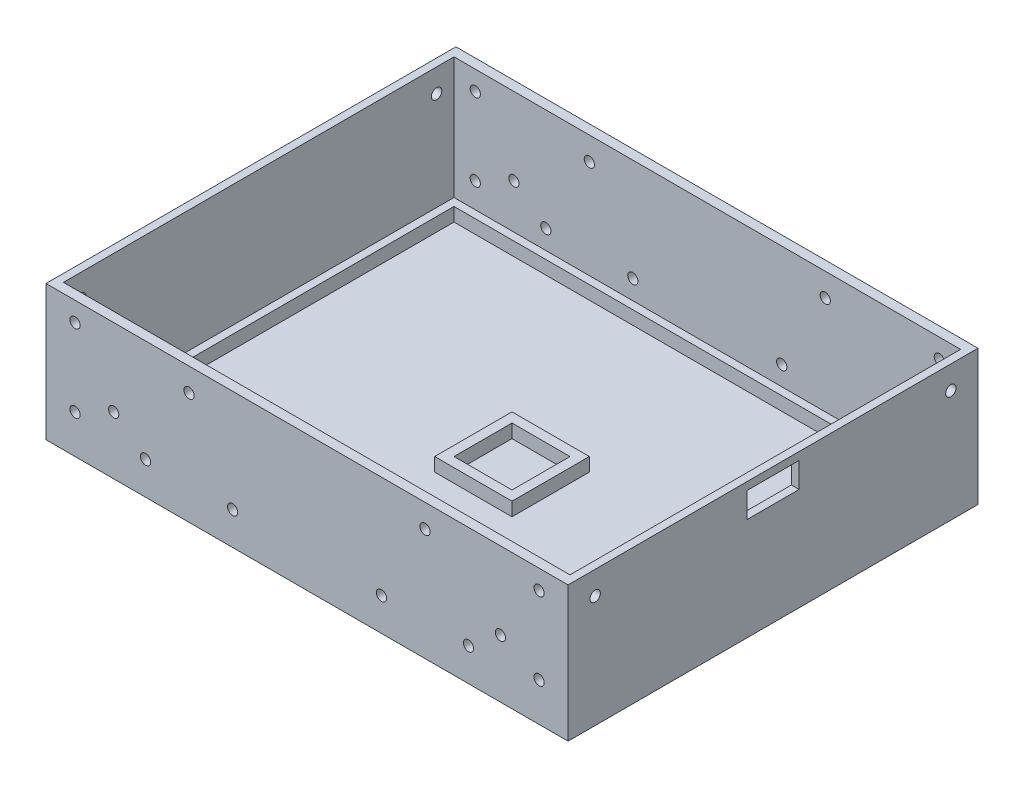
from build123d import *

# Parameters (mm, degrees)
SKETCH1_W               = 270
SKETCH1_H               = 212
BOSS_EXTRUDE1_DEPTH     = 10
SKETCH2_W               = 270
SKETCH2_H               = 212
SKETCH2_W_2             = 262
SKETCH2_H_2             = 202
BOSS_EXTRUDE2_DEPTH     = 70
SKETCH3_W               = 40
SKETCH3_H               = 40
SKETCH3_W_2             = 30
SKETCH3_H_2             = 30
BOSS_EXTRUDE3_DEPTH     = 7
CHAMFER1_SIZE           = 10
SKETCH4_R               = 2.65
CUT_EXTRUDE1_DEPTH      = 207
CIRPATTERN1_COUNT       = 2
MIRROR2_COPY_1_SKETCH_R = 2.65
MIRROR2_COPY_1_DEPTH    = 207
SKETCH5_R               = 2.65
CUT_EXTRUDE2_DEPTH      = 213
FILLET1_R               = 7
SKETCH6_W               = 262
SKETCH6_H               = 202
SKETCH6_W_2             = 254
SKETCH6_H_2             = 194
BOSS_EXTRUDE4_DEPTH     = 7
SKETCH7_W               = 27
SKETCH7_H               = 13
CUT_EXTRUDE3_DEPTH      = 4
CUT_EXTRUDE4_START      = -271
SKETCH8_R               = 2.7
CUT_EXTRUDE4_DEPTH      = 272


with BuildPart() as part:
    # Sketch1 → Boss-Extrude1 (new body)
    with BuildSketch(Plane(origin=(0, 0, 0), x_dir=(1, 0, 0), z_dir=(0, 1, 0))):
        Rectangle(SKETCH1_W, SKETCH1_H)
    extrude(amount=BOSS_EXTRUDE1_DEPTH)

    # Sketch2 → Boss-Extrude2 (add)
    with BuildSketch(Plane(origin=(0, 10, 0), x_dir=(1, 0, 0), z_dir=(0, 1, 0))):
        Rectangle(SKETCH2_W, SKETCH2_H)
        Rectangle(SKETCH2_W_2, SKETCH2_H_2, mode=Mode.SUBTRACT)
    extrude(amount=BOSS_EXTRUDE2_DEPTH)

    # Sketch3 → Boss-Extrude3 (add)
    with BuildSketch(Plane(origin=(0, 10, 0), x_dir=(1, 0, 0), z_dir=(0, 1, 0))):
        Rectangle(SKETCH3_W, SKETCH3_H)
        Rectangle(SKETCH3_W_2, SKETCH3_H_2, mode=Mode.SUBTRACT)
    extrude(amount=BOSS_EXTRUDE3_DEPTH)

    # Chamfer1
    chamfer1_edges = [part.edges().sort_by_distance(p)[0] for p in [
        (0, 0, 106),
        (-135, 0, 0),
        (0, 0, -106),
        (135, 0, 0),
    ]]
    chamfer(chamfer1_edges, length=CHAMFER1_SIZE)

    # Sketch4 → Cut-Extrude1 (cut)
    with BuildSketch(Plane.XY.offset(106)):
        with Locations((83.5, 27)):
            Circle(SKETCH4_R)
        with Locations((38.5, 27)):
            Circle(SKETCH4_R)
        with Locations((61, 68)):
            Circle(SKETCH4_R)
    cut_extrude1 = extrude(amount=-CUT_EXTRUDE1_DEPTH, mode=Mode.SUBTRACT)

    # CirPattern1: Cut-Extrude1 ×2 about axis
    cirpattern1_axis = Axis((0, 84, 0), (0, -1, 0))
    for i in range(1, CIRPATTERN1_COUNT):
        add(cut_extrude1.rotate(cirpattern1_axis, i * 360 / CIRPATTERN1_COUNT), mode=Mode.SUBTRACT)

    # Mirror2: Cut-Extrude1 across plane
    add(cut_extrude1.mirror(Plane(origin=(0, 0, 0), x_dir=(0, 0, 1), z_dir=(1, 0, 0))), mode=Mode.SUBTRACT)

    # Mirror2 copy 1 sketch → Mirror2 copy 1 (cut)
    with BuildSketch(Plane(origin=(0, 0, -106), x_dir=(1, 0, 0), z_dir=(0, 0, -1))):
        with Locations((83.5, -27)):
            Circle(MIRROR2_COPY_1_SKETCH_R)
        with Locations((38.5, -27)):
            Circle(MIRROR2_COPY_1_SKETCH_R)
        with Locations((61, -68)):
            Circle(MIRROR2_COPY_1_SKETCH_R)
    extrude(amount=-MIRROR2_COPY_1_DEPTH, mode=Mode.SUBTRACT)

    # Sketch5 → Cut-Extrude2 (cut, through all)
    with BuildSketch(Plane.XY.offset(106)):
        with Locations((-120, 70)):
            Circle(SKETCH5_R)
        with Locations((-120, 30)):
            Circle(SKETCH5_R)
        with Locations((-100, 40)):
            Circle(SKETCH5_R)
    cut_extrude2 = extrude(amount=-CUT_EXTRUDE2_DEPTH, mode=Mode.SUBTRACT)

    # Mirror1: Cut-Extrude2 across plane
    add(cut_extrude2.mirror(Plane(origin=(0, 0, 0), x_dir=(0, 0, 1), z_dir=(1, 0, 0))), mode=Mode.SUBTRACT)

    # Fillet1
    fillet1_edges = [part.edges().sort_by_distance(p)[0] for p in [
        (125, 0, 0),
        (0, 0, 96),
        (-125, 0, 0),
        (0, 0, -96),
    ]]
    fillet(fillet1_edges, radius=FILLET1_R)

    # Sketch6 → Boss-Extrude4 (add)
    with BuildSketch(Plane(origin=(0, 10, 0), x_dir=(1, 0, 0), z_dir=(0, 1, 0))):
        Rectangle(SKETCH6_W, SKETCH6_H)
        Rectangle(SKETCH6_W_2, SKETCH6_H_2, mode=Mode.SUBTRACT)
    extrude(amount=BOSS_EXTRUDE4_DEPTH)

    # Sketch7 → Cut-Extrude3 (cut)
    with BuildSketch(Plane(origin=(135, 0, 0), x_dir=(0, 0, -1), z_dir=(1, 0, 0))):
        with Locations((0, 69.5)):
            Rectangle(SKETCH7_W, SKETCH7_H)
    extrude(amount=-CUT_EXTRUDE3_DEPTH, mode=Mode.SUBTRACT)

    # Sketch8 → Cut-Extrude4 (cut)
    with BuildSketch(Plane.ZY.offset(135).offset(CUT_EXTRUDE4_START)):
        with Locations((-92, 68)):
            Circle(SKETCH8_R)
    cut_extrude4 = extrude(amount=CUT_EXTRUDE4_DEPTH, mode=Mode.SUBTRACT)

    # Mirror3: Cut-Extrude4 across plane
    add(cut_extrude4.mirror(Plane.XY), mode=Mode.SUBTRACT)


solid = part.part
